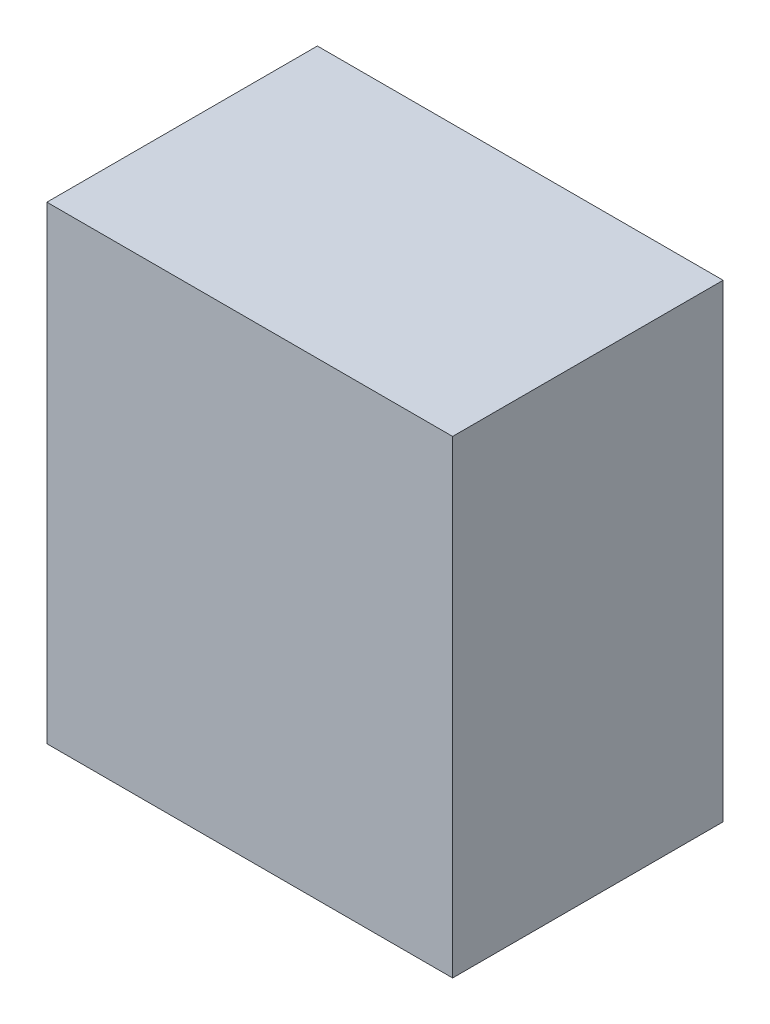
from build123d import *

# Parameters (mm, degrees)
SKETCH1_W                = 750
SKETCH1_H                = 500
BOSS_EXTRUDE1_DEPTH      = 807
BOSS_EXTRUDE1_DEPTH_BACK = 60


with BuildPart() as part:
    # Sketch1 → Boss-Extrude1 (new body, two sides)
    with BuildSketch(Plane(origin=(0, 0, 0), x_dir=(1, 0, 0), z_dir=(0, 1, 0))) as boss_extrude1_sk:
        Rectangle(SKETCH1_W, SKETCH1_H)
    extrude(amount=BOSS_EXTRUDE1_DEPTH)
    extrude(boss_extrude1_sk.sketch, amount=-BOSS_EXTRUDE1_DEPTH_BACK)


solid = part.part
